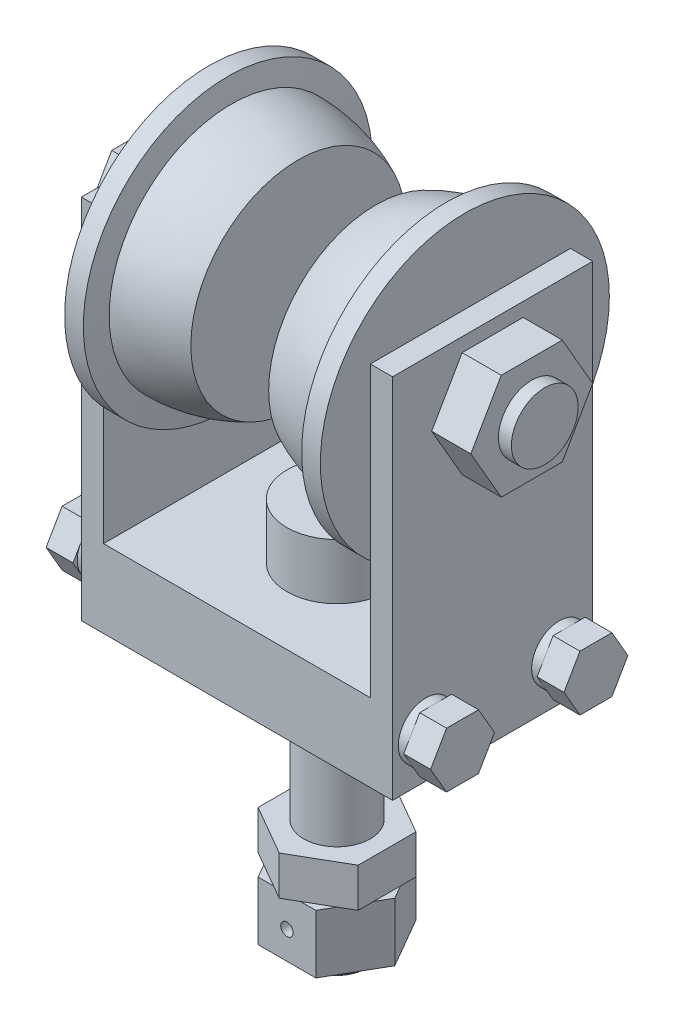
from build123d import *

# Parameters (mm, degrees)
YOKE_CROSS_SECTION_W           = 114.3
YOKE_CROSS_SECTION_H           = 44.45
YOKE_DEPTH                     = 76.2
SIDEPLATE_PROFILE_W            = 114.3
SIDEPLATE_PROFILE_H            = 209.55
SIDEPLATE_DEPTH                = 12.7
WHEEL_PIN_NUT_DEPTH            = 22.352
WHEEL_PIN_PROJECTION_PROFILE_R = 19.05
WHEEL_PIN_PROJECTION_DEPTH     = 7.4168
LOCKNUTS_PROFILE_R             = 15.8115
LOCKNUTS_DEPTH                 = 5.5626
SCREWS_DEPTH                   = 15.3416
PROFILE_R                      = 28.575
KING_BOLT_HEAD_DEPTH           = 31.75
DIA_R                          = 19.05
KING_BOLT_DEPTH                = 82.55
KING_BOLT_JAM_NUT_DEPTH        = 22.352
KING_BOLT_NUT_DEPTH            = 33.4518
SKETCH5_R                      = 19.05
EXTENDED_KING_BOLT_DEPTH       = 9.525
CHAMFER1_SIZE                  = 2.38125
COTTER_PIN_HOLE_REACH          = 113.125
SKETCH7_R                      = 3.571875
SKETCH8_R                      = 30.1625
SKETCH8_R_2                    = 25.4
SPACER_DEPTH                   = 12.7


with BuildPart() as part:
    # YOKE CROSS SECTION → YOKE (new body)
    with BuildSketch(Plane(origin=(0, 0, 0), x_dir=(0, 0, -1), z_dir=(1, 0, 0))):
        with Locations((0, 22.225)):
            Rectangle(YOKE_CROSS_SECTION_W, YOKE_CROSS_SECTION_H)
    extrude(amount=YOKE_DEPTH)

    # SIDEPLATE PROFILE → SIDEPLATE (add)
    with BuildSketch(Plane(origin=(76.2, 0, 0), x_dir=(0, 0, -1), z_dir=(1, 0, 0))):
        with Locations((0, 104.775)):
            Rectangle(SIDEPLATE_PROFILE_W, SIDEPLATE_PROFILE_H)
    extrude(amount=SIDEPLATE_DEPTH)

    # WHEEL PIN NUT PROFILE → WHEEL PIN NUT (add)
    with BuildSketch(Plane(origin=(88.9, 0, 0), x_dir=(0, 0, -1), z_dir=(1, 0, 0))):
        Polygon((34.828654989, 171.45), (17.414327494, 201.6125), (-17.414327494, 201.6125), (-34.828654989, 171.45), (-17.414327494, 141.2875), (17.414327494, 141.2875), align=None)
    extrude(amount=WHEEL_PIN_NUT_DEPTH)

    # WHEEL PIN PROJECTION PROFILE → WHEEL PIN PROJECTION (add)
    with BuildSketch(Plane(origin=(111.252, 0, 0), x_dir=(0, 0, -1), z_dir=(1, 0, 0))):
        with Locations((0, 171.45)):
            Circle(WHEEL_PIN_PROJECTION_PROFILE_R)
    extrude(amount=WHEEL_PIN_PROJECTION_DEPTH)

    # LOCKNUTS PROFILE → LOCKNUTS (add)
    with BuildSketch(Plane(origin=(88.9, 0, 0), x_dir=(0, 0, -1), z_dir=(1, 0, 0))):
        with Locations((-38.1, 25.4)):
            Circle(LOCKNUTS_PROFILE_R)
    locknuts = extrude(amount=LOCKNUTS_DEPTH)

    # SCREWS PROFILE → SCREWS (add)
    with BuildSketch(Plane(origin=(94.4626, 0, 0), x_dir=(0, 0, -1), z_dir=(1, 0, 0))):
        Polygon((-19.842452437, 25.4), (-28.971226219, 41.2115), (-47.228773781, 41.2115), (-56.357547563, 25.4), (-47.228773781, 9.5885), (-28.971226219, 9.5885), align=None)
    screws = extrude(amount=SCREWS_DEPTH)

    # PROFILE → KING BOLT HEAD (add)
    with BuildSketch(Plane(origin=(0, 44.45, 0), x_dir=(-1, 0, 0), z_dir=(0, 1, 0))):
        with Locations(Location((0, 0, 0), (0, 0, 90))):  # turned: the seam where the file's is
            Circle(PROFILE_R)
    extrude(amount=KING_BOLT_HEAD_DEPTH)

    # Mirror1: LOCKNUTS, SCREWS across plane
    add(locknuts.mirror(Plane.XY))
    add(screws.mirror(Plane.XY))

    # Mirror5: part across plane


with BuildPart() as part_1:
    add(part.part)
    add(part.part.mirror(Plane(origin=(0, 0, 0), x_dir=(0, 0, 1), z_dir=(1, 0, 0))))

    # DIA. → KING BOLT (add)
    with BuildSketch(Plane.XZ):
        with Locations(Location((0, 0, 0), (0, 0, 90))):  # turned: the seam where the file's is
            Circle(DIA_R)
    extrude(amount=KING_BOLT_DEPTH)

    # KING BOLT JAN NUT PROFILE → KING BOLT JAM NUT (add)
    with BuildSketch(Plane.XZ.offset(82.55)):
        Polygon((0, -32.995567884), (28.575, -16.497783942), (28.575, 16.497783942), (0, 32.995567884), (-28.575, 16.497783942), (-28.575, -16.497783942), align=None)
    extrude(amount=KING_BOLT_JAM_NUT_DEPTH)

    # KING BOLT NUT PROFILE → KING BOLT NUT (add)
    with BuildSketch(Plane.XZ.offset(104.902)):
        Polygon((32.995567884, 0), (16.497783942, 28.575), (-16.497783942, 28.575), (-32.995567884, 0), (-16.497783942, -28.575), (16.497783942, -28.575), align=None)
    extrude(amount=KING_BOLT_NUT_DEPTH)

    # Sketch5 → EXTENDED KING BOLT (add)
    with BuildSketch(Plane.XZ.offset(138.3538)):
        with Locations(Location((0, 0, 0), (0, 0, 90))):  # turned: the seam where the file's is
            Circle(SKETCH5_R)
    extrude(amount=EXTENDED_KING_BOLT_DEPTH)

    # Chamfer1
    chamfer1_edges = [part_1.edges().sort_by_distance(p)[0] for p in [
        (0, -147.8788, -19.05),
    ]]
    chamfer(chamfer1_edges, length=CHAMFER1_SIZE)

    # Sketch6 → WHEEL (revolve)
    with BuildSketch(Plane.XY, mode=Mode.PRIVATE) as wheel_sk:
        with BuildLine():
            Line((60.325, 241.3), (62.336482392, 254))
            Line((62.336482392, 254), (73.025, 254))
            Line((73.025, 254), (73.025, 198.4375))
            Line((73.025, 198.4375), (76.2, 198.4375))
            Line((76.2, 198.4375), (76.2, 171.45))
            Line((76.2, 171.45), (22.225, 171.45))
            Line((22.225, 171.45), (22.225, 232.721852568))
            ThreePointArc((22.225, 232.721852568), (40.798129966, 239.128953335), (60.325, 241.3))
        make_face()
    wheel = revolve(wheel_sk.sketch.rotate(Axis((76.2, 171.45, 0), (-1, 0, 0)), 90), axis=Axis((76.2, 171.45, 0), (-1, 0, 0)))  # turned: the seam where the file's is

    # Mirror6: WHEEL across plane
    add(wheel.mirror(Plane(origin=(0, 0, 0), x_dir=(0, 0, 1), z_dir=(1, 0, 0))))

    # Sketch7 → COTTER PIN HOLE (cut, up to next)
    with BuildSketch(Plane.XY.offset(28.575), mode=Mode.PRIVATE) as cotter_pin_hole_sk1:
        with Locations((0, -122.4788)):
            Circle(SKETCH7_R)
    cotter_pin_hole_tool1 = extrude(cotter_pin_hole_sk1.sketch, amount=-COTTER_PIN_HOLE_REACH, mode=Mode.PRIVATE) & part_1.part
    add(cotter_pin_hole_tool1.solids().sort_by_distance((0, -122.4788, 28.575))[0], mode=Mode.SUBTRACT)

    # Sketch8 → SPACER (add)
    with BuildSketch(Plane.XZ):
        with Locations(Location((0, 0, 0), (0, 0, 90))):  # turned: the seam where the file's is
            Circle(SKETCH8_R)
        with Locations(Location((0, 0, 0), (0, 0, 270))):  # turned: the seam where the file's is
            Circle(SKETCH8_R_2, mode=Mode.SUBTRACT)
    extrude(amount=SPACER_DEPTH)


solid = part_1.part
